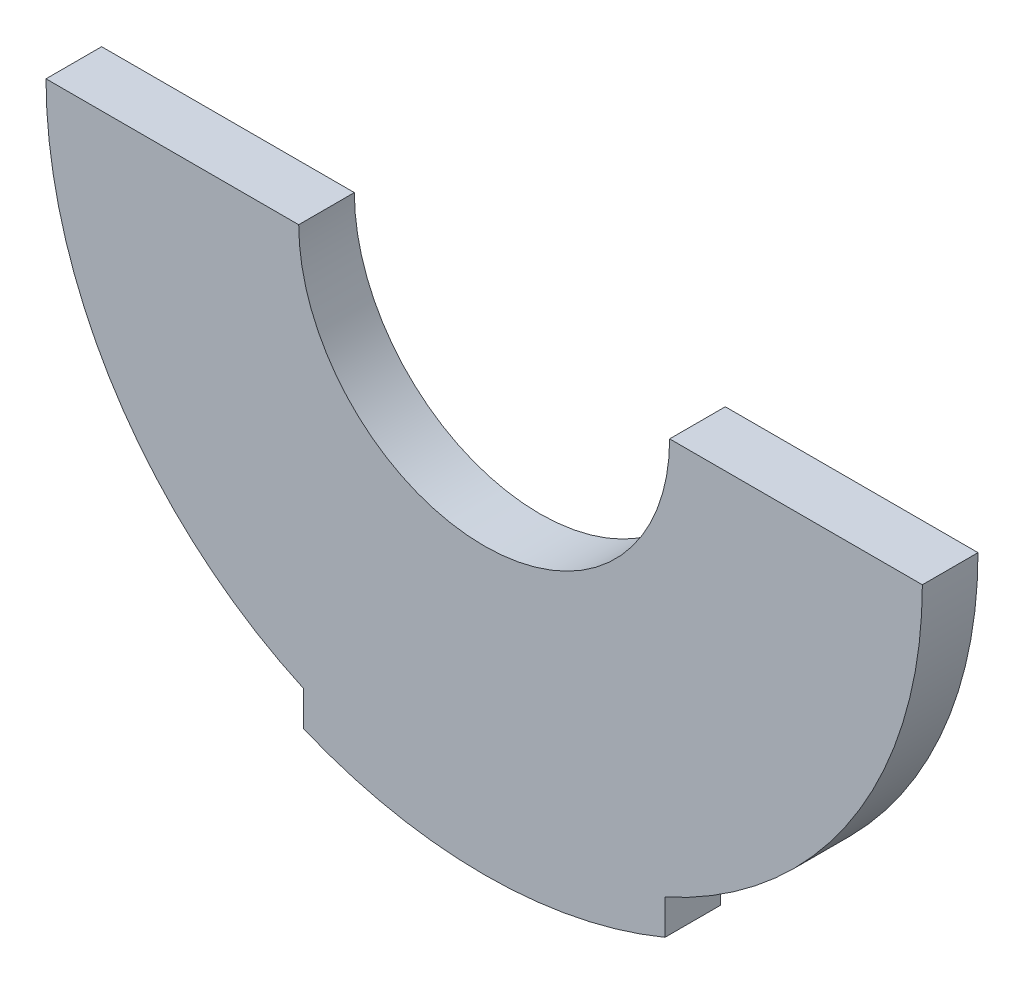
from build123d import *

# Parameters (mm, degrees)
BOSS_EXTRUDE1_DEPTH = 6


with BuildPart() as part:
    # Sketch1 → Boss-Extrude1 (new body)
    with BuildSketch(Plane.XY):
        with BuildLine():
            Line((-47.25, 0), (-20, 0))
            ThreePointArc((-20, 0), (0, -20), (20, 0))
            Line((20, 0), (47.25, 0))
            ThreePointArc((47.25, 0), (39.711065838, -25.604565023), (19.5, -43.038500206))
            Line((19.5, -43.038500206), (19.5, -46.8))
            ThreePointArc((19.5, -46.8), (0, -50.7), (-19.5, -46.8))
            Line((-19.5, -46.8), (-19.5, -43.038500206))
            ThreePointArc((-19.5, -43.038500206), (-39.711065838, -25.604565023), (-47.25, 0))
        make_face()
    extrude(amount=BOSS_EXTRUDE1_DEPTH)


solid = part.part
